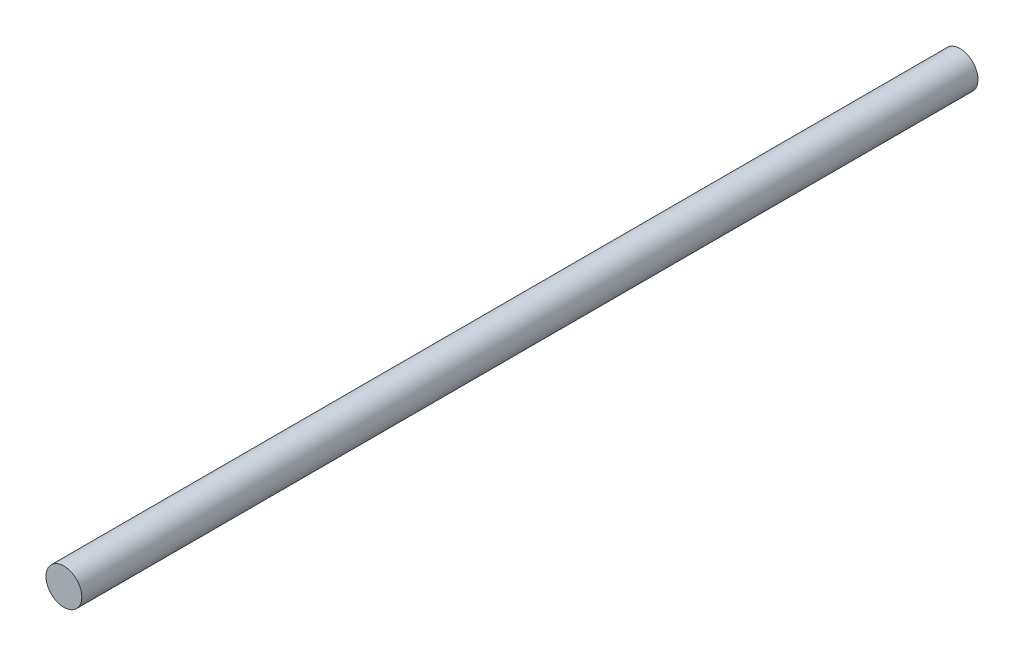
from build123d import *

# Parameters (mm, degrees)
SKETCH_1_R      = 3
EXTRUDE_1_DEPTH = 150


with BuildPart() as part:
    # ｽｹｯﾁ1 → ﾎﾞｽ - 押し出し1 (new body)
    with BuildSketch(Plane.XY):
        Circle(SKETCH_1_R)
    extrude(amount=EXTRUDE_1_DEPTH)


solid = part.part
